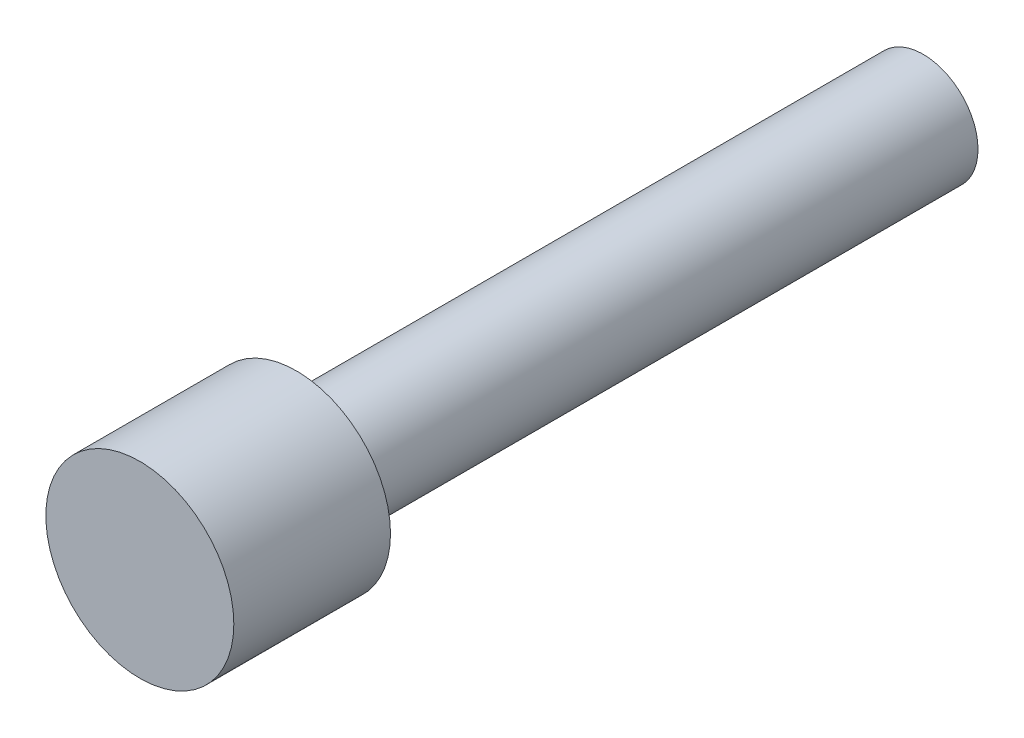
from build123d import *

# Parameters (mm, degrees)
SKETCH1_R           = 1.75
BOSS_EXTRUDE1_DEPTH = 20
SKETCH2_R           = 3
BOSS_EXTRUDE2_DEPTH = 5


with BuildPart() as part:
    # Sketch1 → Boss-Extrude1 (new body)
    with BuildSketch(Plane.XY):
        with Locations((117.212598601, 333.982219225)):
            Circle(SKETCH1_R)
    extrude(amount=BOSS_EXTRUDE1_DEPTH)

    # Sketch2 → Boss-Extrude2 (add)
    with BuildSketch(Plane.XY.offset(20)):
        with Locations((117.212598601, 333.982219225)):
            Circle(SKETCH2_R)
    extrude(amount=BOSS_EXTRUDE2_DEPTH)


solid = part.part
